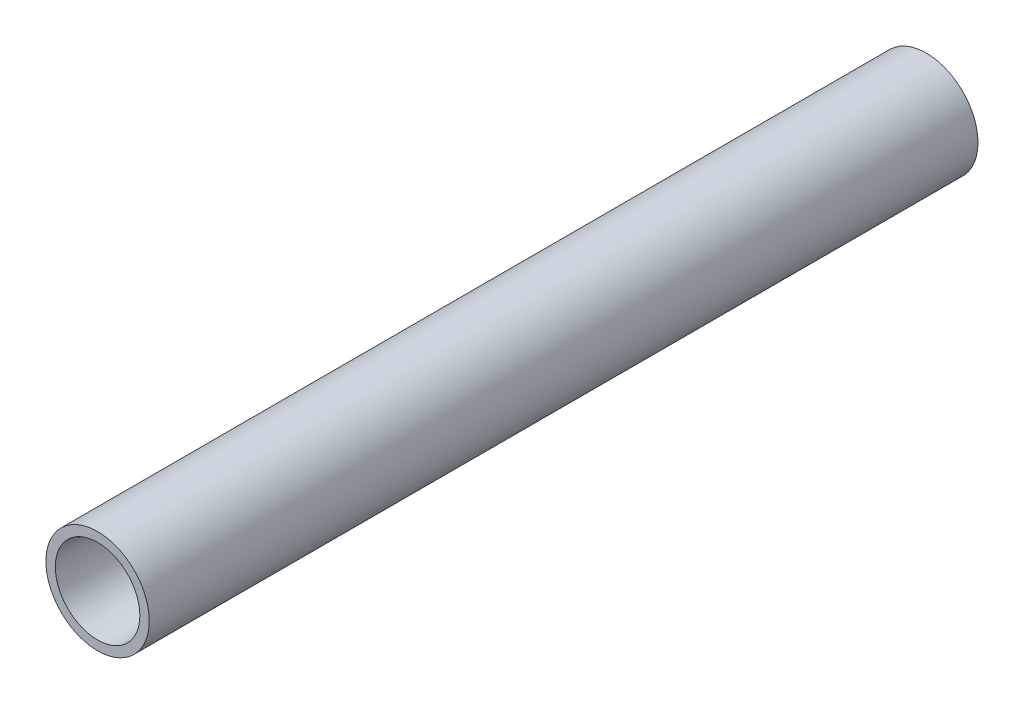
from build123d import *

# Parameters (mm, degrees)
SKETCH1_R           = 2.775
BOSS_EXTRUDE1_DEPTH = 44.5
SKETCH2_R           = 2.27
CUT_EXTRUDE1_DEPTH  = 5.68
CUT_EXTRUDE1_TAPER  = 3.074
SKETCH7_R           = 1
CUT_EXTRUDE2_DEPTH  = 45.5
SKETCH9_R           = 2.27
CUT_EXTRUDE3_DEPTH  = 5.68
CUT_EXTRUDE3_TAPER  = 3.074


with BuildPart() as part:
    # Sketch1 → Boss-Extrude1 (new body)
    with BuildSketch(Plane.XY):
        Circle(SKETCH1_R)
    extrude(amount=BOSS_EXTRUDE1_DEPTH)

    # Sketch2 → Cut-Extrude1 (cut)
    with BuildSketch(Plane.XY):
        Circle(SKETCH2_R)
    extrude(amount=CUT_EXTRUDE1_DEPTH, taper=CUT_EXTRUDE1_TAPER, mode=Mode.SUBTRACT)

    # Sketch7 → Cut-Extrude2 (cut, through all)
    with BuildSketch(Plane.XY):
        Circle(SKETCH7_R)
    extrude(amount=CUT_EXTRUDE2_DEPTH, mode=Mode.SUBTRACT)

    # Sketch9 → Cut-Extrude3 (cut)
    with BuildSketch(Plane.XY.offset(44.5)):
        Circle(SKETCH9_R)
    extrude(amount=-CUT_EXTRUDE3_DEPTH, taper=CUT_EXTRUDE3_TAPER, mode=Mode.SUBTRACT)


solid = part.part
